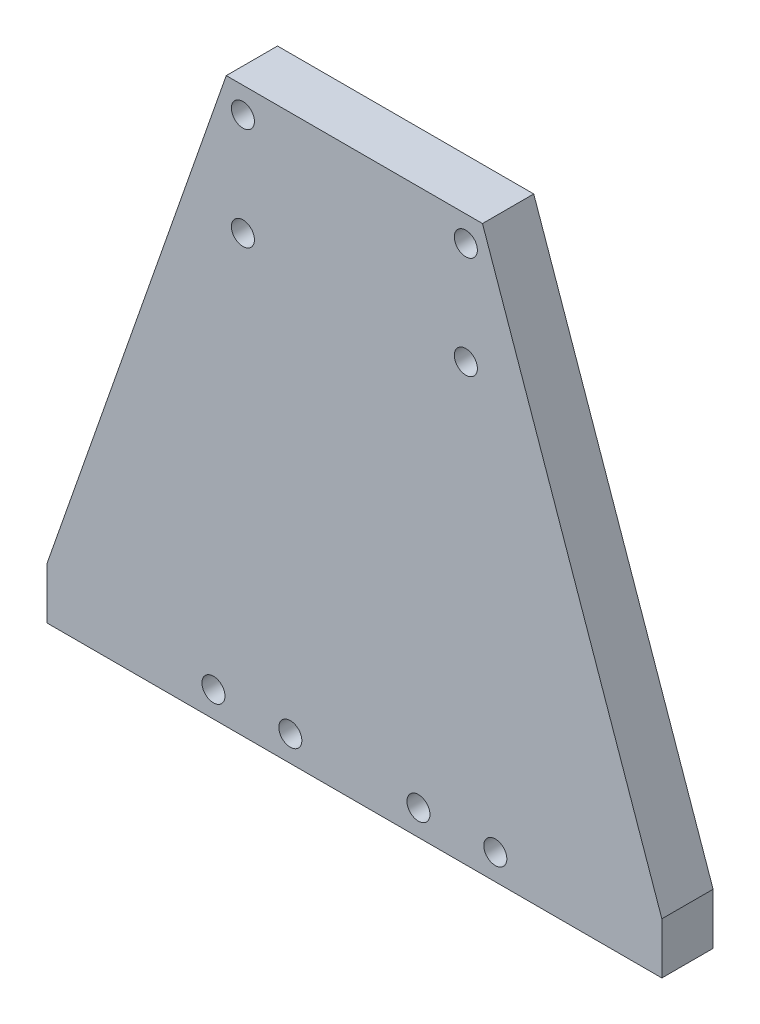
from build123d import *

# Parameters (mm, degrees)
SKETCH1_R           = 2.25
BOSS_EXTRUDE1_DEPTH = 10
SKETCH2_R           = 2.25
CUT_EXTRUDE1_DEPTH  = 11


with BuildPart() as part:
    # Sketch1 → Boss-Extrude1 (new body)
    with BuildSketch(Plane.XY):
        Polygon((-60, -5), (60, -5), (60, 5), (25, 105), (-25, 105), (-60, 5), align=None)
        with Locations((27.5, 0)):
            Circle(SKETCH1_R, mode=Mode.SUBTRACT)
        with Locations((12.5, 0)):
            Circle(SKETCH1_R, mode=Mode.SUBTRACT)
        with Locations((-12.5, 0)):
            Circle(SKETCH1_R, mode=Mode.SUBTRACT)
        with Locations((-27.5, 0)):
            Circle(SKETCH1_R, mode=Mode.SUBTRACT)
    extrude(amount=BOSS_EXTRUDE1_DEPTH)

    # Sketch2 → Cut-Extrude1 (cut, through all)
    with BuildSketch(Plane.XY.offset(10)):
        with Locations((-21.75, 80)):
            Circle(SKETCH2_R)
        with Locations((21.75, 80)):
            Circle(SKETCH2_R)
        with Locations((21.75, 100)):
            Circle(SKETCH2_R)
        with Locations((-21.75, 100)):
            Circle(SKETCH2_R)
    extrude(amount=-CUT_EXTRUDE1_DEPTH, mode=Mode.SUBTRACT)


solid = part.part
